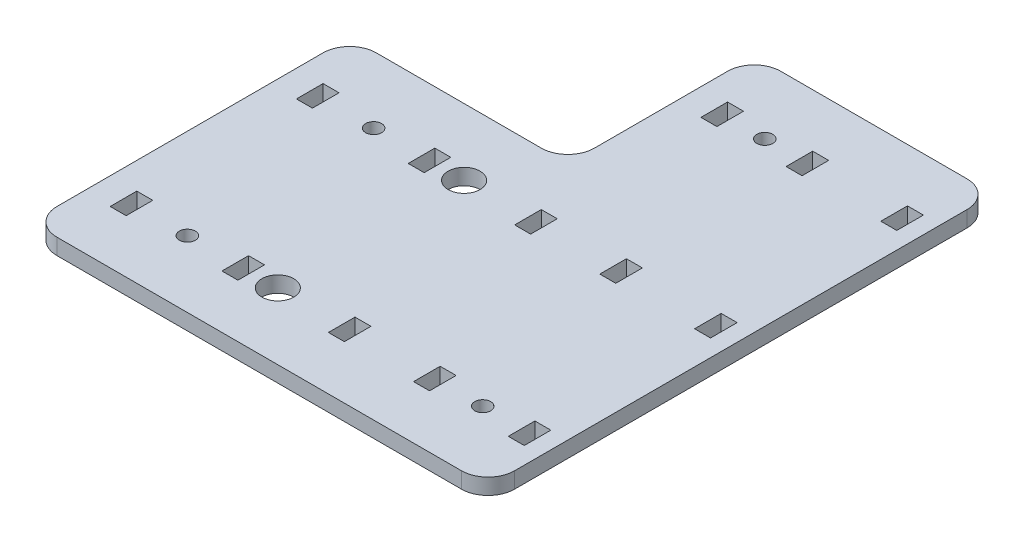
from build123d import *

# Parameters (mm, degrees)
SKETCH1_W           = 86
SKETCH1_H           = 60
BOSS_EXTRUDE1_DEPTH = 3
SKETCH4_W           = 45
SKETCH4_H           = 3
BOSS_EXTRUDE2_DEPTH = 35
SKETCH2_W           = 3
SKETCH2_H           = 5
CUT_EXTRUDE1_DEPTH  = 3
SKETCH8_W           = 3
SKETCH8_H           = 5
CUT_EXTRUDE10_DEPTH = 4
LPATTERN3_COUNT     = 2
LPATTERN3_PITCH     = 35
FILLET1_R           = 5
LPATTERN1_COUNT     = 3
LPATTERN1_PITCH     = 35
SKETCH5_R           = 1.5
CUT_EXTRUDE2_DEPTH  = 4
SKETCH6_R           = 3
CUT_EXTRUDE3_DEPTH  = 4


with BuildPart() as part:
    # Sketch1 → Boss-Extrude1 (new body)
    with BuildSketch(Plane(origin=(0, 0, 0), x_dir=(1, 0, 0), z_dir=(0, 1, 0))):
        with Locations((43, 30)):
            Rectangle(SKETCH1_W, SKETCH1_H)
    extrude(amount=BOSS_EXTRUDE1_DEPTH)

    # Sketch4 → Boss-Extrude2 (add)
    with BuildSketch(Plane(origin=(0, 0, -60), x_dir=(-1, 0, 0), z_dir=(0, 0, -1))):
        with Locations((-63.5, 1.5)):
            Rectangle(SKETCH4_W, SKETCH4_H)
    extrude(amount=BOSS_EXTRUDE2_DEPTH)

    # Sketch2 → Cut-Extrude1 (cut)
    with BuildSketch(Plane(origin=(0, 3, 0), x_dir=(1, 0, 0), z_dir=(0, 1, 0))):
        with Locations((63.5, 12.5)):
            Rectangle(SKETCH2_W, SKETCH2_H)
        with Locations((47.5, 12.5)):
            Rectangle(SKETCH2_W, SKETCH2_H)
        with Locations((81.3, 12.5)):
            Rectangle(SKETCH2_W, SKETCH2_H)
    cut_extrude1 = extrude(amount=-CUT_EXTRUDE1_DEPTH, mode=Mode.SUBTRACT)

    # Sketch8 → Cut-Extrude10 (cut, through all)
    with BuildSketch(Plane(origin=(0, 3, 0), x_dir=(1, 0, 0), z_dir=(0, 1, 0))):
        with Locations((6.5, 12.5)):
            Rectangle(SKETCH8_W, SKETCH8_H)
        with Locations((27.5, 12.5)):
            Rectangle(SKETCH8_W, SKETCH8_H)
    cut_extrude10 = extrude(amount=-CUT_EXTRUDE10_DEPTH, mode=Mode.SUBTRACT)

    # LPattern3: Cut-Extrude10 ×2
    with Locations(*[(0, 0, -i * LPATTERN3_PITCH) for i in range(1, LPATTERN3_COUNT)]):
        add(cut_extrude10, mode=Mode.SUBTRACT)

    # Fillet1
    fillet1_edges = [part.edges().sort_by_distance(p)[0] for p in [
        (41, 1.5, -60),
        (86, 1.5, -95),
        (41, 1.5, -95),
        (0, 1.5, -60),
        (86, 1.5, 0),
        (0, 1.5, 0),
    ]]
    fillet(fillet1_edges, radius=FILLET1_R)

    # LPattern1: Cut-Extrude1 ×3
    with Locations(*[(0, 0, -i * LPATTERN1_PITCH) for i in range(1, LPATTERN1_COUNT)]):
        add(cut_extrude1, mode=Mode.SUBTRACT)

    # Sketch5 → Cut-Extrude2 (cut, through all)
    with BuildSketch(Plane(origin=(0, 3, 0), x_dir=(1, 0, 0), z_dir=(0, 1, 0))):
        with Locations((17, 12.5)):
            Circle(SKETCH5_R)
        with Locations((17, 47.5)):
            Circle(SKETCH5_R)
        with Locations((72.5, 12.5)):
            Circle(SKETCH5_R)
        with Locations((55.5, 82.5)):
            Circle(SKETCH5_R)
    extrude(amount=-CUT_EXTRUDE2_DEPTH, mode=Mode.SUBTRACT)

    # Sketch6 → Cut-Extrude3 (cut, through all)
    with BuildSketch(Plane(origin=(0, 3, 0), x_dir=(1, 0, 0), z_dir=(0, 1, 0))):
        with Locations((34, 12.5)):
            Circle(SKETCH6_R)
        with Locations((34, 47.5)):
            Circle(SKETCH6_R)
    extrude(amount=-CUT_EXTRUDE3_DEPTH, mode=Mode.SUBTRACT)


solid = part.part
